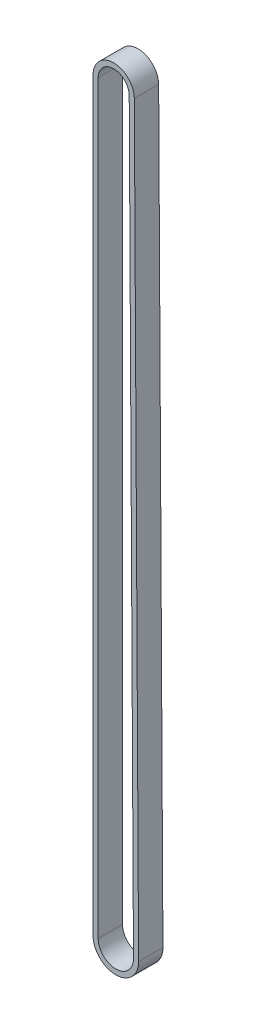
from build123d import *

# Parameters (mm, degrees)
BOSS_EXTRUDE1_DEPTH = 6.2


with BuildPart() as part:
    # Sketch1 → Boss-Extrude1 (new body)
    with BuildSketch(Plane.XY):
        with BuildLine():
            Line((324.756453181, -302.445914232), (324.756453181, -112.552615583))
            ThreePointArc((324.756453181, -112.552615583), (329.9959613, -107.298037255), (335.26556649, -112.522431946))
            Line((335.26556649, -112.522431946), (336.356357491, -302.412597691))
            ThreePointArc((336.356357491, -302.412597691), (330.57311152, -308.245890309), (324.756453181, -302.445914232))
        make_face()
        with BuildLine():
            Line((326.056453181, -302.445914232), (326.056453181, -112.552615583))
            ThreePointArc((326.056453181, -112.552615583), (329.999695066, -108.598031893), (333.965587938, -112.529899446))
            Line((333.965587938, -112.529899446), (335.056378939, -302.420065192))
            ThreePointArc((335.056378939, -302.420065192), (330.569377754, -306.945895671), (326.056453181, -302.445914232))
        make_face(mode=Mode.SUBTRACT)
    extrude(amount=-BOSS_EXTRUDE1_DEPTH)


solid = part.part
